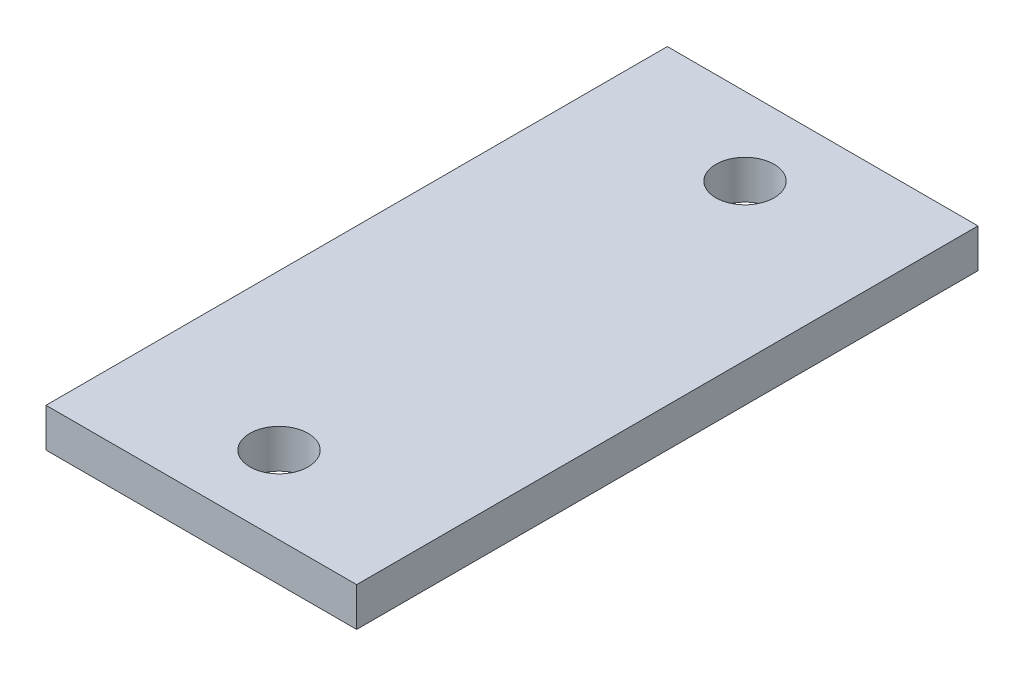
from build123d import *

# Parameters (mm, degrees)
SKETCH1_W    = 50.8
SKETCH1_H    = 101.6
SKETCH1_R    = 4.7625
HAMMER_DEPTH = 6.35


with BuildPart() as part:
    # Sketch1 → Hammer (new body)
    with BuildSketch(Plane(origin=(0, 0, 0), x_dir=(1, 0, 0), z_dir=(0, 1, 0))):
        with Locations((25.4, 50.8)):
            Rectangle(SKETCH1_W, SKETCH1_H)
        with Locations((25.4, 12.7)):
            Circle(SKETCH1_R, mode=Mode.SUBTRACT)
        with Locations((25.4, 88.9)):
            Circle(SKETCH1_R, mode=Mode.SUBTRACT)
    extrude(amount=HAMMER_DEPTH)


solid = part.part
